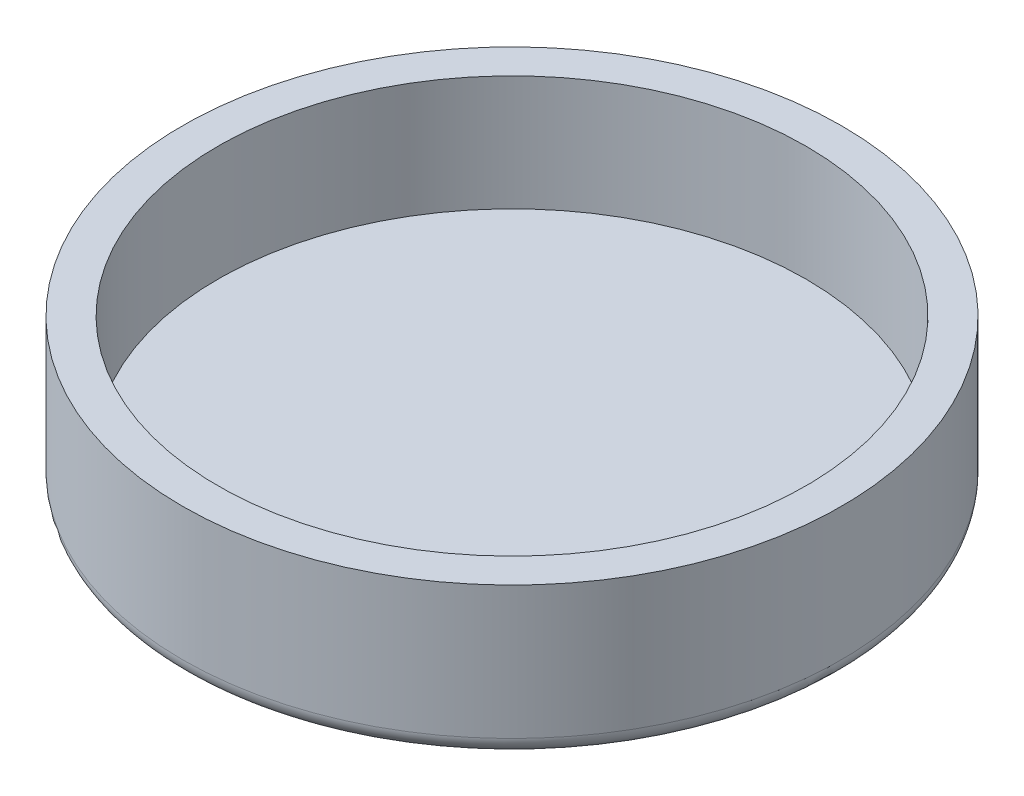
from build123d import *


with BuildPart() as part:
    # Sketch1 → Revolve1 (revolve)
    with BuildSketch(Plane.XY):
        with BuildLine():
            Line((0, 0), (-8.8, 0))
            ThreePointArc((-8.8, 0), (-9.153553391, 0.146446609), (-9.3, 0.5))
            Line((-9.3, 0.5), (-9.3, 4.25))
            Line((-9.3, 4.25), (-8.3, 4.25))
            Line((-8.3, 4.25), (-8.3, 1))
            Line((-8.3, 1), (-1, 1))
            Line((-1, 1), (0, 1))
            Line((0, 1), (0, 0.9))
            Line((0, 0.9), (0, 0))
        make_face()
    revolve(axis=Axis((0, 1, 0), (0, 1, 0)))


solid = part.part
